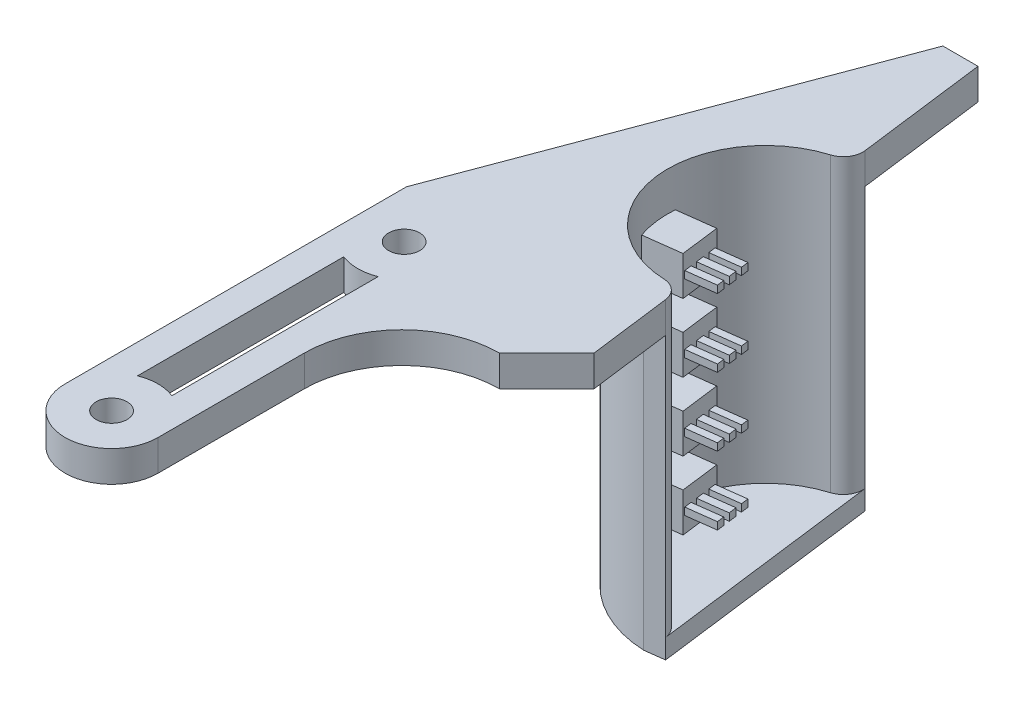
from build123d import *
from build123d.topology import SkipClean

# Parameters (mm, degrees)
CROQUIS1_R               = 1.5875
SALIENTE_EXTRUIR1_DEPTH  = 3.175
CORTAR_EXTRUIR1_DEPTH    = 3.175
CORTAR_EXTRUIR3_DEPTH    = 10
CROQUIS5_R               = 10
CORTAR_EXTRUIR8_DEPTH    = 10
REDONDEO2_R              = 2
BOSS_EXTRUDE1_DEPTH      = 30
BOSS_EXTRUDE2_DEPTH      = 2
BOSS_EXTRUDE6_REACH      = 54.664
BOSS_EXTRUDE6_END_RADIUS = 10
SKETCH7_W                = 4
SKETCH7_H                = 4
SKETCH9_W                = 0.75
SKETCH9_H                = 0.75
SKETCH9_W_2              = 0.804911676
BOSS_EXTRUDE7_DEPTH      = 3
LPATTERN1_COUNT          = 4
LPATTERN1_PITCH          = 7


with BuildPart() as part:
    # Croquis1 → Saliente-Extruir1 (new body)
    with BuildSketch(Plane(origin=(0, 0, 0), x_dir=(1, 0, 0), z_dir=(0, 1, 0))):
        with BuildLine():
            Line((-12.5, 0), (-12.5, -40))
            Line((-12.5, -40), (-2.975, -40))
            Line((-2.975, -40), (-2.975, -20))
            ThreePointArc((-2.975, -20), (-0.046067812, -12.928932188), (7.025, -10))
            Line((7.025, -10), (12.5, -10))
            Line((12.5, -10), (12.5, 40))
            Line((12.5, 40), (2.5, 40))
            Line((2.5, 40), (-12.5, 0))
        make_face()
        with Locations(Location((-7.7375, -5, 0), (0, 0, 270))):
            Circle(CROQUIS1_R, mode=Mode.SUBTRACT)
        with Locations(Location((-7.7375, -35, 0), (0, 0, 270))):
            Circle(CROQUIS1_R, mode=Mode.SUBTRACT)
    extrude(amount=SALIENTE_EXTRUIR1_DEPTH)

    # Croquis2 → Cortar-Extruir1 (cut)
    with BuildSketch(Plane(origin=(0, 3.175, 0), x_dir=(1, 0, 0), z_dir=(0, 1, 0))):
        Polygon((12.5, -10), (6.1, 40), (12.5, 40), align=None)
    extrude(amount=-CORTAR_EXTRUIR1_DEPTH, mode=Mode.SUBTRACT)

    # Croquis3 → Cortar-Extruir3 (cut)
    with BuildSketch(Plane(origin=(0, 3.175, 0), x_dir=(1, 0, 0), z_dir=(0, 1, 0))):
        with BuildLine():
            ThreePointArc((-5.975, -30.575635639), (-7.7375, -30.2375), (-9.5, -30.575635639))
            Line((-9.5, -30.575635639), (-9.5, -9.427055314))
            ThreePointArc((-9.5, -9.427055314), (-7.7375, -9.765), (-5.975, -9.427055314))
            Line((-5.975, -9.427055314), (-5.975, -14.803847577))
            Line((-5.975, -14.803847577), (-5.975, -30.575635639))
        make_face()
        with BuildLine():
            ThreePointArc((-12.5, -35), (-7.7375, -39.7625), (-2.975, -35))
            Line((-2.975, -35), (-2.975, -40))
            Line((-2.975, -40), (-12.5, -40))
            Line((-12.5, -40), (-12.5, -35))
        make_face()
    extrude(amount=-CORTAR_EXTRUIR3_DEPTH, mode=Mode.SUBTRACT)

    # Croquis5 → Cortar-Extruir8 (cut)
    with BuildSketch(Plane(origin=(0, 3.175, 0), x_dir=(1, 0, 0), z_dir=(0, 1, 0))):
        with Locations((9.3, 15)):
            Circle(CROQUIS5_R)
        Polygon((7.025, -10), (11.878723404, -5.146276596), (12.5, -10), align=None)
    extrude(amount=-CORTAR_EXTRUIR8_DEPTH, mode=Mode.SUBTRACT)

    # Redondeo2
    redondeo2_edges = [part.edges().sort_by_distance(p)[0] for p in [
        (8.030358645, 1.5875, -24.919073083),
        (10.569641355, 1.5875, -5.080926917),
    ]]
    fillet(redondeo2_edges, radius=REDONDEO2_R)

    # Sketch1 → Boss-Extrude1 (add)
    with SkipClean():  # the faces are left unmerged after this step: merging them gives an invalid solid
        with BuildSketch(Plane(origin=(0, 3.175, 0), x_dir=(1, 0, 0), z_dir=(0, 1, 0))):
            with BuildLine():
                Line((7.79774009, 26.736405547), (5.813925473, 26.482477276))
                ThreePointArc((5.813925473, 26.482477276), (-2.6028877, 13.476430374), (8.818445293, 3.009666182))
                Line((8.818445293, 3.009666182), (10.80225991, 3.263594453))
                ThreePointArc((10.80225991, 3.263594453), (10.16969874, 4.484153931), (8.898704411, 5.008055152))
                ThreePointArc((8.898704411, 5.008055152), (-0.619073083, 13.730358645), (6.394937894, 24.568731063))
                ThreePointArc((6.394937894, 24.568731063), (7.492998908, 25.395871368), (7.79774009, 26.736405547))
            make_face()
        extrude(amount=-BOSS_EXTRUDE1_DEPTH)

    # Sketch2 → Boss-Extrude2 (add)
    with SkipClean():  # the faces are left unmerged after this step: merging them gives an invalid solid
        with BuildSketch(Plane.XZ.offset(26.825)):
            with BuildLine():
                Line((10.80225991, -3.263594453), (7.79774009, -26.736405547))
                Line((7.79774009, -26.736405547), (5.813925473, -26.482477276))
                ThreePointArc((5.813925473, -26.482477276), (-2.6028877, -13.476430374), (8.818445293, -3.009666182))
                Line((8.818445293, -3.009666182), (10.80225991, -3.263594453))
            make_face()
        extrude(amount=BOSS_EXTRUDE2_DEPTH)

    # Boss-Extrude6: up to this cylinder (the profile starts inside it)
    with SkipClean():  # the faces are left unmerged after this step: merging them gives an invalid solid
        boss_extrude6_end = Plane(origin=(9.3, -23.825, -15), z_dir=(0, 1, 0)) * Cylinder(BOSS_EXTRUDE6_END_RADIUS, 130.328, mode=Mode.PRIVATE)
        # Sketch7 → Boss-Extrude6 (add, up to the surface)
        with BuildSketch(Plane(origin=(5.087690965, 0, -0.651224444), x_dir=(-0.12696413546540503, 0, -0.9919073083234755), z_dir=(0.9919073083234755, 0, -0.12696413546540503)), mode=Mode.PRIVATE) as boss_extrude6_sk1:
            with Locations((13.697843165, -23.825)):
                Rectangle(SKETCH7_W, SKETCH7_H)
        boss_extrude6_tool1 = extrude(boss_extrude6_sk1.sketch, amount=-BOSS_EXTRUDE6_REACH, mode=Mode.PRIVATE) & boss_extrude6_end
        boss_extrude6 = boss_extrude6_tool1.solids().sort_by_distance((3.348556, -23.825, -14.238215))[0]
        add(boss_extrude6)

    # Sketch9 → Boss-Extrude7 (add)
    with SkipClean():  # the faces are left unmerged after this step: merging them gives an invalid solid
        with BuildSketch(Plane(origin=(5.087690965, 0, -0.651224444), x_dir=(-0.12696413546540508, 0, -0.9919073083234755), z_dir=(0.9919073083234755, 0, -0.12696413546540508))):
            with Locations((15.125299003, -23.825)):
                Rectangle(SKETCH9_W, SKETCH9_H)
            with Locations((13.697843165, -23.825)):
                Rectangle(SKETCH9_W_2, SKETCH9_H)
            with Locations((12.270387327, -23.825)):
                Rectangle(SKETCH9_W, SKETCH9_H)
        boss_extrude7 = extrude(amount=BOSS_EXTRUDE7_DEPTH)

    # LPattern1: Boss-Extrude6, Boss-Extrude7 ×4
    with SkipClean():  # the faces are left unmerged after this step: merging them gives an invalid solid
        with Locations(*[(0, i * LPATTERN1_PITCH, 0) for i in range(1, LPATTERN1_COUNT)]):
            add(boss_extrude6)
            add(boss_extrude7)


solid = part.part
